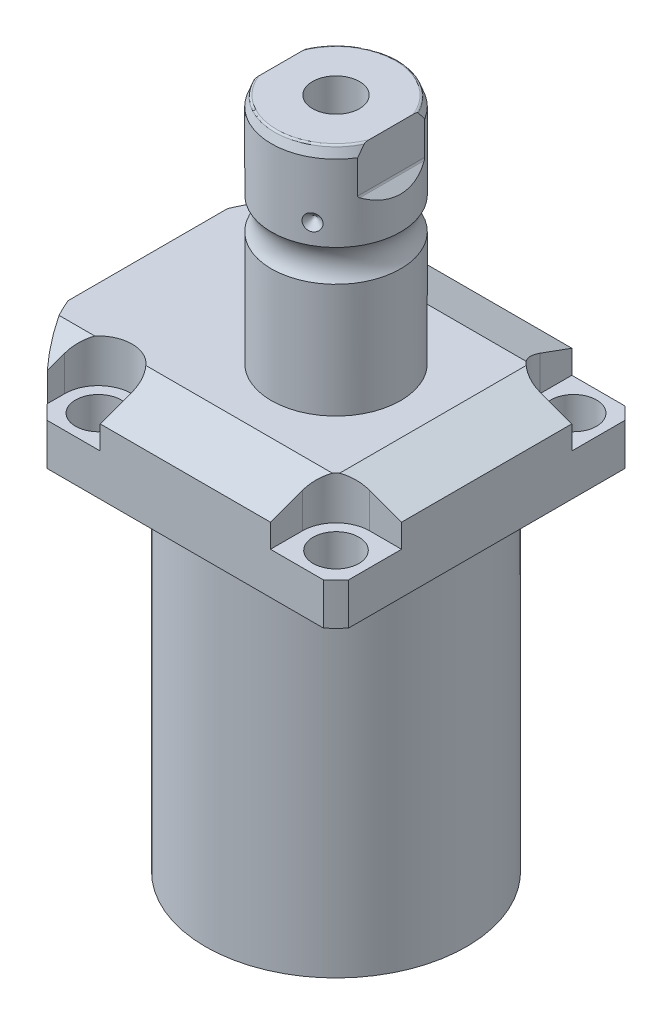
from build123d import *

# Parameters (mm, degrees)
SKETCH1_W               = 88.9
SKETCH1_H               = 99.9998
EXTRUDE1_DEPTH          = 129.794
SKETCH2_OUTSIDE_W       = 139.282
SKETCH2_OUTSIDE_H       = 128.182
SKETCH2_OUTSIDE_R       = 60.325
CUT_EXTRUDE1_DEPTH      = 130.794
SKETCH3_W               = 38.1
SKETCH3_H               = 104.775
FILLET1_R               = 0.381
CUT_EXTRUDE2_DEPTH      = 12.7
CUT_EXTRUDE9_START      = -56.5498
CUT_EXTRUDE9_DEPTH      = 101.9998
CUT_EXTRUDE7_DEPTH      = 45.45
CUT_EXTRUDE7_DEPTH_BACK = 45.45
SKETCH10_R              = 1.1811
SKETCH11_R              = 1.1811
LPATTERN1_COUNT         = 2
LPATTERN1_PITCH         = 25.9588
CUT_EXTRUDE8_DEPTH      = 53.34
SKETCH17_W              = 6.7437
SKETCH17_H              = 12.319
HOLE1_AT_2_COUNT        = 2
HOLE1_AT_2_PITCH        = 70.104
HOLE1_AT_3_COUNT        = 2
HOLE1_AT_3_PITCH        = 99.142027577
HOLE1_AT_4_COUNT        = 2
HOLE1_AT_4_PITCH        = 70.104
CHAMFER1_SIZE           = 0.635
FILLET2_R               = 0.635
CIRPATTERN1_COUNT       = 3


with BuildPart() as part:
    # Sketch1 → Extrude1 (new body)
    with BuildSketch(Plane.ZX):
        with Locations((0, -5.5499)):
            Rectangle(SKETCH1_W, SKETCH1_H)
    extrude(amount=EXTRUDE1_DEPTH)

    # Sketch2 outside → Cut-Extrude1 (cut, through all)
    with BuildSketch(Plane.XZ):
        with Locations((-5.55, 0)):
            Rectangle(SKETCH2_OUTSIDE_W, SKETCH2_OUTSIDE_H)
        Circle(SKETCH2_OUTSIDE_R, mode=Mode.SUBTRACT)
    extrude(amount=-CUT_EXTRUDE1_DEPTH, mode=Mode.SUBTRACT)

    # Sketch3 → Cut-Revolve1 (revolve, cut)
    with BuildSketch(Plane(origin=(0, 0, 0), x_dir=(0, 0, 1), z_dir=(1, 0, 0))):
        with Locations((57.5437, -52.3875)):
            Rectangle(SKETCH3_W, SKETCH3_H)
    revolve(axis=Axis((0, 93.345, 0), (0, -1, 0)), mode=Mode.SUBTRACT)

    # Fillet1
    fillet1_edges = [part.edges().sort_by_distance(p)[0] for p in [
        (0, 104.775, -38.4937),
    ]]
    fillet(fillet1_edges, radius=FILLET1_R)

    # Sketch4 → Cut-Extrude2 (cut)
    with BuildSketch(Plane(origin=(0, 129.794, 0), x_dir=(-1, 0, 0), z_dir=(0, 1, 0))):
        with BuildLine():
            Line((-25.1206, -44.45), (-25.1206, -35.052))
            ThreePointArc((-25.1206, -35.052), (-28.029439713, -28.029439713), (-35.052, -25.1206))
            Line((-35.052, -25.1206), (-44.45, -25.1206))
            Line((-44.45, -25.1206), (-44.45, -44.45))
            Line((-44.45, -44.45), (-25.1206, -44.45))
        make_face()
        with BuildLine():
            Line((44.9834, -44.45), (25.1206, -44.45))
            Line((25.1206, -44.45), (25.1206, -35.052))
            ThreePointArc((25.1206, -35.052), (35.052, -25.1206), (44.9834, -35.052))
            Line((44.9834, -35.052), (44.9834, -44.45))
        make_face()
        with BuildLine():
            Line((25.1206, 44.45), (25.1206, 35.052))
            ThreePointArc((25.1206, 35.052), (35.052, 25.1206), (44.9834, 35.052))
            Line((44.9834, 35.052), (44.9834, 44.45))
            Line((44.9834, 44.45), (25.1206, 44.45))
        make_face()
        with BuildLine():
            Line((-35.052, 25.1206), (-44.45, 25.1206))
            Line((-44.45, 25.1206), (-44.45, 44.45))
            Line((-44.45, 44.45), (-25.1206, 44.45))
            Line((-25.1206, 44.45), (-25.1206, 35.052))
            ThreePointArc((-25.1206, 35.052), (-28.029439713, 28.029439713), (-35.052, 25.1206))
        make_face()
    extrude(amount=-CUT_EXTRUDE2_DEPTH, mode=Mode.SUBTRACT)

    # Sketch5 → Cut-Extrude9 (cut)
    with BuildSketch(Plane(origin=(0, 0, 0), x_dir=(0, 0, -1), z_dir=(1, 0, 0)).offset(CUT_EXTRUDE9_START)):
        Polygon((-28.575, 129.794), (-44.45, 124.015972531), (-44.45, 129.794), align=None)
    cut_extrude9 = extrude(amount=CUT_EXTRUDE9_DEPTH, mode=Mode.SUBTRACT)

    # Mirror1: Cut-Extrude9 across plane
    add(cut_extrude9.mirror(Plane.XY), mode=Mode.SUBTRACT)

    # Sketch9 → Cut-Extrude7 (cut, two sides)
    with BuildSketch(Plane.XY) as cut_extrude7_sk:
        Polygon((28.575, 129.794), (44.45, 124.015972531), (44.45, 129.794), align=None)
    extrude(amount=CUT_EXTRUDE7_DEPTH, mode=Mode.SUBTRACT)
    extrude(cut_extrude7_sk.sketch, amount=-CUT_EXTRUDE7_DEPTH_BACK, mode=Mode.SUBTRACT)

    # Sketch20 → Cut-Revolve4 (revolve, cut)
    with BuildSketch(Plane(origin=(-41.402, 88.9, -18.1102), x_dir=(0, 1, 0), z_dir=(1, 0, 0)), mode=Mode.PRIVATE) as cut_revolve4_sk:
        Polygon((15.875, 41.9227), (17.3228, 41.9227), (17.3228, 39.4716), (18.3388, 39.4716), (18.3388, 37.465), (29.3116, 37.465), (29.3116, 36.2204), (15.875, 36.2204), align=None)
    cut_revolve4 = revolve(cut_revolve4_sk.sketch.rotate(Axis((-41.402, 81.620304954, 18.1102), (0, 1, 0)), 180), axis=Axis((-41.402, 81.620304954, 18.1102), (0, 1, 0)), mode=Mode.SUBTRACT)  # turned: the seam where the file's is

    # Mirror10: Cut-Revolve4 across plane
    add(cut_revolve4.mirror(Plane.XY), mode=Mode.SUBTRACT)

    # S2D0007 → Cut-Revolve2 (revolve, cut)
    with BuildSketch(Plane(origin=(-55.5498, 101.9048, 12.9794), x_dir=(0, 1, 0), z_dir=(0, 0, 1)), mode=Mode.PRIVATE) as cut_revolve2_sk:
        Polygon((15.875, 0), (26.3525, 0), (26.3525, -0.254), (22.0599, -0.254), (21.517306865, -2.8067), (20.8534, -3.470606865), (20.8534, -14.224), (15.875, -14.224), align=None)
    cut_revolve2 = revolve(cut_revolve2_sk.sketch.rotate(Axis((-40.6146, 117.7798, 12.9794), (-1, 0, 0)), 90), axis=Axis((-40.6146, 117.7798, 12.9794), (-1, 0, 0)), mode=Mode.SUBTRACT)  # turned: the seam where the file's is

    # LPattern1: Cut-Revolve2 ×2
    with Locations(*[(0, 0, -i * LPATTERN1_PITCH) for i in range(1, LPATTERN1_COUNT)]):
        add(cut_revolve2, mode=Mode.SUBTRACT)

    # Sketch15 → Revolve3 (revolve)
    with BuildSketch(Plane(origin=(0, 0, 0), x_dir=(0, -1, 0), z_dir=(1, 0, 0)), mode=Mode.PRIVATE) as revolve3_sk:
        with BuildLine():
            Line((-129.794, 0), (-129.794, 19.05))
            Line((-129.794, 19.05), (-163.46630643, 19.05))
            ThreePointArc((-163.46630643, 19.05), (-168.1734, 17.5006), (-172.88049357, 19.05))
            Line((-172.88049357, 19.05), (-195.4276, 19.05))
            Line((-195.4276, 19.05), (-198.3486, 17.986842946))
            Line((-198.3486, 17.986842946), (-198.3486, 0))
            Line((-198.3486, 0), (-129.794, 0))
        make_face()
    revolve(revolve3_sk.sketch.rotate(Axis((0, 197.63613, 0), (0, -1, 0)), 180), axis=Axis((0, 197.63613, 0), (0, -1, 0)))  # turned: the seam where the file's is

    # Sketch16 → Cut-Extrude8 (cut, symmetric)
    with BuildSketch(Plane(origin=(0, 0, 0), x_dir=(0, -1, 0), z_dir=(0, 0, -1))):
        with BuildLine():
            Line((-198.3486, 19.05), (-182.564369265, 19.05))
            Line((-182.564369265, 19.05), (-185.109784633, 16.504584633))
            ThreePointArc((-185.109784633, 16.504584633), (-185.356995225, 16.339403796), (-185.6486, 16.2814))
            Line((-185.6486, 16.2814), (-198.3486, 16.2814))
            Line((-198.3486, 16.2814), (-198.3486, 19.05))
        make_face()
        with BuildLine():
            Line((-198.3486, -19.05), (-198.3486, -16.2814))
            Line((-198.3486, -16.2814), (-185.6486, -16.2814))
            ThreePointArc((-185.6486, -16.2814), (-185.356995225, -16.339403796), (-185.109784633, -16.504584633))
            Line((-185.109784633, -16.504584633), (-182.564369265, -19.05))
            Line((-182.564369265, -19.05), (-198.3486, -19.05))
        make_face()
    extrude(amount=CUT_EXTRUDE8_DEPTH, both=True, mode=Mode.SUBTRACT)

    # Sketch17 → Hole1 (revolve, cut)
    with BuildSketch(Plane(origin=(35.052, 117.094, -35.052), x_dir=(0, 0, 1), z_dir=(1, 0, 0))):
        with Locations((3.37185, 6.1595)):
            Rectangle(SKETCH17_W, SKETCH17_H)
    hole1 = revolve(axis=Axis((35.052, 7.094, -35.052), (0, 1, 0)), mode=Mode.SUBTRACT)

    # Hole1 at 2: Hole1 ×2
    with Locations(*[(0, 0, i * HOLE1_AT_2_PITCH) for i in range(1, HOLE1_AT_2_COUNT)]):
        add(hole1, mode=Mode.SUBTRACT)

    # Hole1 at 3: Hole1 ×2
    with Locations(*[Vector(-0.707106781, 0, 0.707106781) * (i * HOLE1_AT_3_PITCH) for i in range(1, HOLE1_AT_3_COUNT)]):
        add(hole1, mode=Mode.SUBTRACT)

    # Hole1 at 4: Hole1 ×2
    with Locations(*[(-i * HOLE1_AT_4_PITCH, 0, 0) for i in range(1, HOLE1_AT_4_COUNT)]):
        add(hole1, mode=Mode.SUBTRACT)

    # Chamfer1
    chamfer1_edges = [part.edges().sort_by_distance(p)[0] for p in [
        (-41.402, 107.2388, 19.3548),
        (-41.402, 107.2388, -19.3548),
    ]]
    chamfer(chamfer1_edges, length=CHAMFER1_SIZE)

    # Sketch21 → Cut-Revolve5 (revolve, cut)
    with BuildSketch(Plane.XY, mode=Mode.PRIVATE) as cut_revolve5_sk:
        Polygon((0, 172.9486), (6.9342, 177.115087704), (6.9342, 198.3486), (0, 198.3486), align=None)
    revolve(cut_revolve5_sk.sketch.rotate(Axis((0, 0, 0), (0, 1, 0)), 270), axis=Axis((0, 0, 0), (0, 1, 0)), mode=Mode.SUBTRACT)  # turned: the seam where the file's is

    # Fillet2
    fillet2_edges = [part.edges().sort_by_distance(p)[0] for p in [
        (0, 198.3486, 17.986842946),
        (0, 198.3486, -17.986842946),
    ]]
    fillet(fillet2_edges, radius=FILLET2_R)

    # Sketch22 → Cut-Revolve6 (revolve, cut)
    with BuildSketch(Plane.XY, mode=Mode.PRIVATE) as cut_revolve6_sk:
        Polygon((-19.05, 181.2544), (-16.637, 178.8414), (-19.05, 178.8414), align=None)
    cut_revolve6 = revolve(cut_revolve6_sk.sketch.rotate(Axis((-37.997376206, 178.8414, 0), (1, 0, 0)), 90), axis=Axis((-37.997376206, 178.8414, 0), (1, 0, 0)), mode=Mode.SUBTRACT)  # turned: the seam where the file's is

    # CirPattern1: Cut-Revolve6 ×3 about axis
    cirpattern1_axis = Axis((0, 197.63613, 0), (0, 1, 0))
    for i in range(1, CIRPATTERN1_COUNT):
        add(cut_revolve6.rotate(cirpattern1_axis, i * 360 / CIRPATTERN1_COUNT), mode=Mode.SUBTRACT)


with BuildPart() as body_2:
    # Sketch10 → Revolve4 (revolve)
    with BuildSketch(Plane(origin=(-41.402, 88.9, -18.1102), x_dir=(0, 1, 0), z_dir=(1, 0, 0))):
        with Locations((16.1417, 4.5212)):
            Circle(SKETCH10_R)
    revolve(axis=Axis((-41.402, 87.86749, -18.1102), (0, 1, 0)))


with BuildPart() as body_3:
    # Sketch11 → Revolve2 (revolve)
    with BuildSketch(Plane(origin=(-41.402, 88.9, 18.1102), x_dir=(0, 1, 0), z_dir=(1, 0, 0)), mode=Mode.PRIVATE) as revolve2_sk:
        with Locations((16.1417, 4.5212)):
            Circle(SKETCH11_R)
    revolve(revolve2_sk.sketch.rotate(Axis((-41.402, 87.86749, 18.1102), (0, 1, 0)), 180), axis=Axis((-41.402, 87.86749, 18.1102), (0, 1, 0)))  # turned: the seam where the file's is


solid = Compound([part.part, body_2.part, body_3.part])
